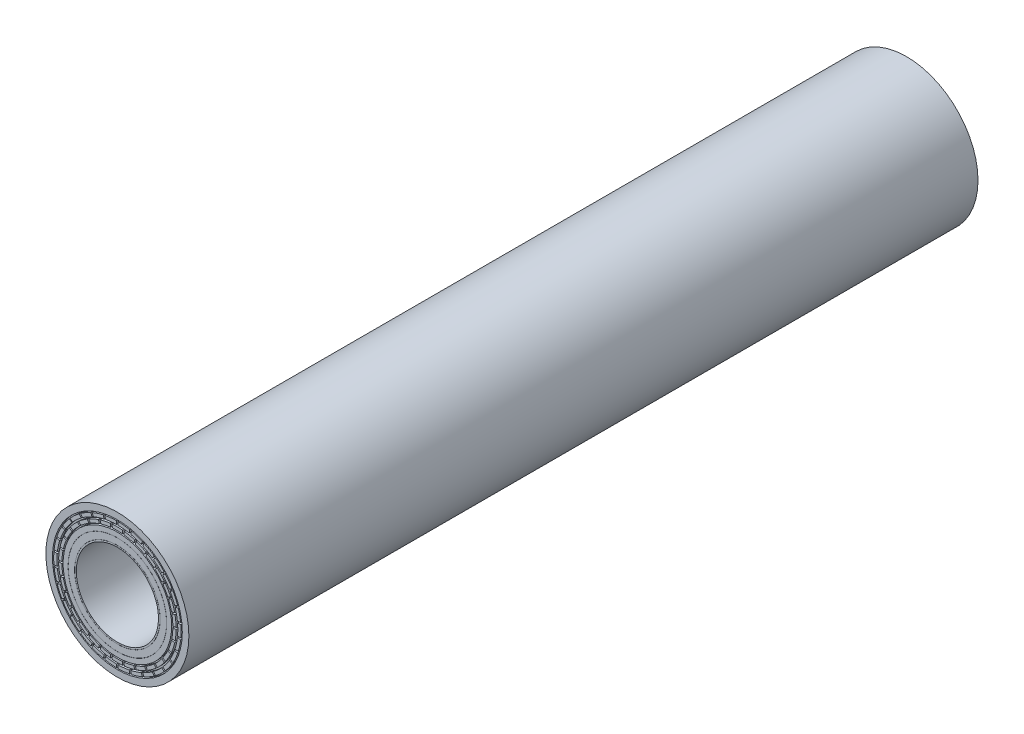
from build123d import *

# Parameters (mm, degrees)
SKETCH1_R           = 87
BOSS_EXTRUDE1_DEPTH = 960
SKETCH2_R           = 52
CUT_EXTRUDE1_DEPTH  = 961
SKETCH3_R           = 79
SKETCH3_R_2         = 77.5
SKETCH3_R_3         = 73.5
SKETCH3_R_4         = 71.5
SKETCH3_R_5         = 67.5
SKETCH3_R_6         = 66
CUT_EXTRUDE2_DEPTH  = 3
SKETCH7_W           = 1
SKETCH7_H           = 5.5
CUT_EXTRUDE5_DEPTH  = 3
SKETCH8_W           = 5.5
SKETCH8_H           = 2
CUT_EXTRUDE6_DEPTH  = 3
SKETCH9_R           = 52
SKETCH9_R_2         = 50
BOSS_EXTRUDE2_DEPTH = 960
SKETCH10_R          = 52
SKETCH10_R_2        = 51.9
CUT_EXTRUDE7_DEPTH  = 1
SKETCH11_R          = 52.1
SKETCH11_R_2        = 52
CUT_EXTRUDE8_DEPTH  = 1
SKETCH12_R          = 60
SKETCH12_R_2        = 59.9
CUT_EXTRUDE9_DEPTH  = 1


with BuildPart() as part:
    # Sketch1 → Boss-Extrude1 (new body)
    with BuildSketch(Plane.XY):
        with Locations((0, 87)):
            Circle(SKETCH1_R)
    extrude(amount=-BOSS_EXTRUDE1_DEPTH)

    # Sketch2 → Cut-Extrude1 (cut, through all)
    with BuildSketch(Plane.XY):
        with Locations((0, 87)):
            Circle(SKETCH2_R)
    extrude(amount=-CUT_EXTRUDE1_DEPTH, mode=Mode.SUBTRACT)

    # Sketch3 → Cut-Extrude2 (cut)
    with BuildSketch(Plane.XY):
        with Locations((0, 87)):
            Circle(SKETCH3_R)
        with Locations((0, 87)):
            Circle(SKETCH3_R_2, mode=Mode.SUBTRACT)
        with Locations((0, 87)):
            Circle(SKETCH3_R_3)
        with Locations((0, 87)):
            Circle(SKETCH3_R_4, mode=Mode.SUBTRACT)
        with Locations((0, 87)):
            Circle(SKETCH3_R_5)
        with Locations((0, 87)):
            Circle(SKETCH3_R_6, mode=Mode.SUBTRACT)
    cut_extrude2 = extrude(amount=-CUT_EXTRUDE2_DEPTH, mode=Mode.SUBTRACT)

    # Mirror2: Cut-Extrude2 across plane
    add(cut_extrude2.mirror(Plane.XY.offset(-480)), mode=Mode.SUBTRACT)

    # Sketch7 → Cut-Extrude5 (cut)
    with BuildSketch(Plane.XY):
        Polygon((-16.051745185, 16.292210638), (-17.195259485, 10.912398834), (-16.217111884, 10.704487143), (-15.073597584, 16.084298947), align=None)
        Polygon((-15.073597584, 16.084298947), (-16.217111884, 10.704487143), (-15.238964283, 10.496575452), (-14.095449984, 15.876387256), align=None)
        Polygon((14.095449984, 15.876387256), (15.238964283, 10.496575452), (16.217111884, 10.704487143), (15.073597584, 16.084298947), align=None)
        Polygon((15.073597584, 16.084298947), (16.217111884, 10.704487143), (17.195259485, 10.912398834), (16.051745185, 16.292210638), align=None)
        Polygon((28.574861165, 20.361217678), (30.811912702, 15.336717661), (31.72545816, 15.743454304), (29.488406623, 20.767954321), align=None)
        Polygon((29.488406623, 20.767954321), (31.72545816, 15.743454304), (32.639003618, 16.150190947), (30.401952081, 21.174690964), align=None)
        Polygon((-30.401952081, 21.174690964), (-32.639003618, 16.150190947), (-31.72545816, 15.743454304), (-29.488406623, 20.767954321), align=None)
        Polygon((-29.488406623, 20.767954321), (-31.72545816, 15.743454304), (-30.811912702, 15.336717661), (-28.574861165, 20.361217678), align=None)
        Polygon((-43.423447786, 28.93405316), (-46.656266673, 24.484459691), (-45.847249679, 23.896674439), (-42.614430791, 28.346267908), align=None)
        Polygon((-42.614430791, 28.346267908), (-45.847249679, 23.896674439), (-45.038232684, 23.308889186), (-41.805413797, 27.758482656), align=None)
        Polygon((-54.547130453, 39.231175864), (-58.634426994, 35.550957529), (-57.965296387, 34.807812704), (-53.877999847, 38.488031039), align=None)
        Polygon((-63.286841774, 51.616025404), (-68.049981495, 48.866025404), (-67.549981495, 48), (-62.786841774, 50.75), align=None)
        Polygon((-62.786841774, 50.75), (-67.549981495, 48), (-67.049981495, 47.133974596), (-62.286841774, 49.883974596), align=None)
        Polygon((-69.260614426, 65.547324424), (-74.491425265, 63.847730955), (-74.182408271, 62.896674439), (-68.951597431, 64.596267908), align=None)
        Polygon((-68.951597431, 64.596267908), (-74.182408271, 62.896674439), (-73.873391277, 61.945617922), (-68.642580437, 63.645211392), align=None)
        Polygon((-72.207365877, 80.416208308), (-77.677236302, 79.84130176), (-77.572707839, 78.846779865), (-72.102837414, 79.421686413), align=None)
        Polygon((-72.102837414, 79.421686413), (-77.572707839, 78.846779865), (-77.468179375, 77.85225797), (-71.998308951, 78.427164518), align=None)
        Polygon((-71.998308951, 95.572835482), (-77.468179375, 96.14774203), (-77.572707839, 95.153220135), (-72.102837414, 94.578313587), align=None)
        Polygon((-72.102837414, 94.578313587), (-77.572707839, 95.153220135), (-77.677236302, 94.15869824), (-72.207365877, 93.583791692), align=None)
        Polygon((-68.642580437, 110.354788608), (-73.873391277, 112.054382078), (-74.182408271, 111.103325561), (-68.951597431, 109.403732092), align=None)
        Polygon((-68.951597431, 109.403732092), (-74.182408271, 111.103325561), (-74.491425265, 110.152269045), (-69.260614426, 108.452675576), align=None)
        Polygon((-62.786841774, 123.25), (-67.549981495, 126), (-68.049981495, 125.133974596), (-63.286841774, 122.383974596), align=None)
        Polygon((-62.286841774, 124.116025404), (-67.049981495, 126.866025404), (-67.549981495, 126), (-62.786841774, 123.25), align=None)
        Polygon((-53.877999847, 135.511968961), (-57.965296387, 139.192187296), (-58.634426994, 138.449042471), (-54.547130453, 134.768824136), align=None)
        Polygon((-42.614430791, 145.653732092), (-45.847249679, 150.103325561), (-46.656266673, 149.515540309), (-43.423447786, 145.06594684), align=None)
        Polygon((-41.805413797, 146.241517344), (-45.038232684, 150.691110814), (-45.847249679, 150.103325561), (-42.614430791, 145.653732092), align=None)
        Polygon((-29.488406623, 153.232045679), (-31.72545816, 158.256545696), (-32.639003618, 157.849809053), (-30.401952081, 152.825309036), align=None)
        Polygon((-28.574861165, 153.638782322), (-30.811912702, 158.663282339), (-31.72545816, 158.256545696), (-29.488406623, 153.232045679), align=None)
        Polygon((-15.073597584, 157.915701053), (-16.217111884, 163.295512857), (-17.195259485, 163.087601166), (-16.051745185, 157.707789362), align=None)
        Polygon((-14.095449984, 158.123612744), (-15.238964283, 163.503424548), (-16.217111884, 163.295512857), (-15.073597584, 157.915701053), align=None)
        with Locations((-0.5, 162.25)):
            Rectangle(SKETCH7_W, SKETCH7_H)
        with Locations((0.5, 162.25)):
            Rectangle(SKETCH7_W, SKETCH7_H)
        Polygon((15.073597584, 157.915701053), (16.217111884, 163.295512857), (15.238964283, 163.503424548), (14.095449984, 158.123612744), align=None)
        Polygon((16.051745185, 157.707789362), (17.195259485, 163.087601166), (16.217111884, 163.295512857), (15.073597584, 157.915701053), align=None)
        Polygon((29.488406623, 153.232045679), (31.72545816, 158.256545696), (30.811912702, 158.663282339), (28.574861165, 153.638782322), align=None)
        Polygon((30.401952081, 152.825309036), (32.639003618, 157.849809053), (31.72545816, 158.256545696), (29.488406623, 153.232045679), align=None)
        Polygon((42.614430791, 145.653732092), (45.847249679, 150.103325561), (45.038232684, 150.691110814), (41.805413797, 146.241517344), align=None)
        Polygon((43.423447786, 145.06594684), (46.656266673, 149.515540309), (45.847249679, 150.103325561), (42.614430791, 145.653732092), align=None)
        Polygon((53.877999847, 135.511968961), (57.965296387, 139.192187296), (57.296165781, 139.935332121), (53.208869241, 136.255113786), align=None)
        Polygon((54.547130453, 134.768824136), (58.634426994, 138.449042471), (57.965296387, 139.192187296), (53.877999847, 135.511968961), align=None)
        Polygon((62.786841774, 123.25), (67.549981495, 126), (67.049981495, 126.866025404), (62.286841774, 124.116025404), align=None)
        Polygon((63.286841774, 122.383974596), (68.049981495, 125.133974596), (67.549981495, 126), (62.786841774, 123.25), align=None)
        Polygon((68.951597431, 109.403732092), (74.182408271, 111.103325561), (73.873391277, 112.054382078), (68.642580437, 110.354788608), align=None)
        Polygon((69.260614426, 108.452675576), (74.491425265, 110.152269045), (74.182408271, 111.103325561), (68.951597431, 109.403732092), align=None)
        Polygon((72.102837414, 94.578313587), (77.572707839, 95.153220135), (77.468179375, 96.14774203), (71.998308951, 95.572835482), align=None)
        Polygon((72.207365877, 93.583791692), (77.677236302, 94.15869824), (77.572707839, 95.153220135), (72.102837414, 94.578313587), align=None)
        Polygon((68.951597431, 64.596267908), (74.182408271, 62.896674439), (74.491425265, 63.847730955), (69.260614426, 65.547324424), align=None)
        Polygon((68.642580437, 63.645211392), (73.873391277, 61.945617922), (74.182408271, 62.896674439), (68.951597431, 64.596267908), align=None)
        Polygon((72.102837414, 79.421686413), (77.572707839, 78.846779865), (77.677236302, 79.84130176), (72.207365877, 80.416208308), align=None)
        Polygon((71.998308951, 78.427164518), (77.468179375, 77.85225797), (77.572707839, 78.846779865), (72.102837414, 79.421686413), align=None)
        Polygon((62.786841774, 50.75), (67.549981495, 48), (68.049981495, 48.866025404), (63.286841774, 51.616025404), align=None)
        Polygon((62.286841774, 49.883974596), (67.049981495, 47.133974596), (67.549981495, 48), (62.786841774, 50.75), align=None)
        Polygon((53.877999847, 38.488031039), (57.965296387, 34.807812704), (58.634426994, 35.550957529), (54.547130453, 39.231175864), align=None)
        Polygon((53.208869241, 37.744886214), (57.296165781, 34.064667879), (57.965296387, 34.807812704), (53.877999847, 38.488031039), align=None)
        Polygon((41.805413797, 27.758482656), (45.038232684, 23.308889186), (45.847249679, 23.896674439), (42.614430791, 28.346267908), align=None)
        Polygon((42.614430791, 28.346267908), (45.847249679, 23.896674439), (46.656266673, 24.484459691), (43.423447786, 28.93405316), align=None)
        with Locations((-0.5, 11.75)):
            Rectangle(SKETCH7_W, SKETCH7_H)
        with Locations((0.5, 11.75)):
            Rectangle(SKETCH7_W, SKETCH7_H)
    cut_extrude5 = extrude(amount=-CUT_EXTRUDE5_DEPTH, mode=Mode.SUBTRACT)

    # Mirror3: Cut-Extrude5 across plane
    add(cut_extrude5.mirror(Plane.XY.offset(-480)), mode=Mode.SUBTRACT)

    # Sketch8 → Cut-Extrude6 (cut)
    with BuildSketch(Plane.XY):
        with Locations((-69.25, 87)):
            Rectangle(SKETCH8_W, SKETCH8_H)
        Polygon((-64.838903758, 101.80427504), (-70.218715562, 102.94778934), (-70.634538944, 100.991494138), (-65.25472714, 99.847979839), align=None)
        Polygon((-60.34403629, 114.961532222), (-65.368536307, 117.198583759), (-66.182009593, 115.371492844), (-61.157509576, 113.134441307), align=None)
        Polygon((-53.211844874, 126.896736272), (-57.661438343, 130.129555159), (-58.837008847, 128.511521171), (-54.387415378, 125.278702283), align=None)
        Polygon((-43.754040497, 137.088261501), (-47.434258832, 141.175558041), (-48.920548483, 139.837296828), (-45.240330148, 135.750000288), align=None)
        Polygon((-32.383974596, 145.090689352), (-35.133974596, 149.853829072), (-36.866025404, 148.853829072), (-34.116025404, 144.090689352), align=None)
        Polygon((-19.59857361, 150.554275328), (-21.298167079, 155.785086168), (-23.200280111, 155.167052179), (-21.500686642, 149.936241339), align=None)
        Polygon((-5.956620912, 153.240234505), (-6.53152746, 158.71010493), (-8.520571251, 158.501048003), (-7.945664703, 153.031177579), align=None)
        Polygon((7.945664703, 153.031177579), (8.520571251, 158.501048003), (6.53152746, 158.71010493), (5.956620912, 153.240234505), align=None)
        Polygon((21.500686642, 149.936241339), (23.200280111, 155.167052179), (21.298167079, 155.785086168), (19.59857361, 150.554275328), align=None)
        Polygon((34.116025404, 144.090689352), (36.866025404, 148.853829072), (35.133974596, 149.853829072), (32.383974596, 145.090689352), align=None)
        Polygon((45.240330148, 135.750000288), (48.920548483, 139.837296828), (47.434258832, 141.175558041), (43.754040497, 137.088261501), align=None)
        Polygon((54.387415378, 125.278702283), (58.837008847, 128.511521171), (57.661438343, 130.129555159), (53.211844874, 126.896736272), align=None)
        Polygon((61.157509576, 113.134441307), (66.182009593, 115.371492844), (65.368536307, 117.198583759), (60.34403629, 114.961532222), align=None)
        Polygon((65.25472714, 99.847979839), (70.634538944, 100.991494138), (70.218715562, 102.94778934), (64.838903758, 101.80427504), align=None)
        with Locations((69.25, 87)):
            Rectangle(SKETCH8_W, SKETCH8_H)
        Polygon((64.838903758, 72.19572496), (70.218715562, 71.05221066), (70.634538944, 73.008505862), (65.25472714, 74.152020161), align=None)
        Polygon((60.34403629, 59.038467778), (65.368536307, 56.801416241), (66.182009593, 58.628507156), (61.157509576, 60.865558693), align=None)
        Polygon((53.211844874, 47.103263728), (57.661438343, 43.870444841), (58.837008847, 45.488478829), (54.387415378, 48.721297717), align=None)
        Polygon((43.754040497, 36.911738499), (47.434258832, 32.824441959), (48.920548483, 34.162703172), (45.240330148, 38.249999712), align=None)
        Polygon((32.383974596, 28.909310648), (35.133974596, 24.146170928), (36.866025404, 25.146170928), (34.116025404, 29.909310648), align=None)
        Polygon((19.59857361, 23.445724672), (21.298167079, 18.214913832), (23.200280111, 18.832947821), (21.500686642, 24.063758661), align=None)
        Polygon((5.956620912, 20.759765495), (6.53152746, 15.28989507), (8.520571251, 15.498951997), (7.945664703, 20.968822421), align=None)
        Polygon((-7.945664703, 20.968822421), (-8.520571251, 15.498951997), (-6.53152746, 15.28989507), (-5.956620912, 20.759765495), align=None)
        Polygon((-21.500686642, 24.063758661), (-23.200280111, 18.832947821), (-21.298167079, 18.214913832), (-19.59857361, 23.445724672), align=None)
        Polygon((-34.116025404, 29.909310648), (-36.866025404, 25.146170928), (-35.133974596, 24.146170928), (-32.383974596, 28.909310648), align=None)
        Polygon((-45.240330148, 38.249999712), (-48.920548483, 34.162703172), (-47.434258832, 32.824441959), (-43.754040497, 36.911738499), align=None)
        Polygon((-54.387415378, 48.721297717), (-58.837008847, 45.488478829), (-57.661438343, 43.870444841), (-53.211844874, 47.103263728), align=None)
        Polygon((-61.157509576, 60.865558693), (-66.182009593, 58.628507156), (-65.368536307, 56.801416241), (-60.34403629, 59.038467778), align=None)
        Polygon((-65.25472714, 74.152020161), (-70.634538944, 73.008505862), (-70.218715562, 71.05221066), (-64.838903758, 72.19572496), align=None)
    cut_extrude6 = extrude(amount=-CUT_EXTRUDE6_DEPTH, mode=Mode.SUBTRACT)

    # Mirror4: Cut-Extrude6 across plane
    add(cut_extrude6.mirror(Plane.XY.offset(-480)), mode=Mode.SUBTRACT)

    # Sketch9 → Boss-Extrude2 (add)
    with BuildSketch(Plane.XY):
        with Locations((0, 87)):
            Circle(SKETCH9_R)
        with Locations((0, 87)):
            Circle(SKETCH9_R_2, mode=Mode.SUBTRACT)
    extrude(amount=-BOSS_EXTRUDE2_DEPTH)

    # Sketch10 → Cut-Extrude7 (cut)
    with BuildSketch(Plane.XY):
        with Locations((0, 87)):
            Circle(SKETCH10_R)
        with Locations((0, 87)):
            Circle(SKETCH10_R_2, mode=Mode.SUBTRACT)
    extrude(amount=-CUT_EXTRUDE7_DEPTH, mode=Mode.SUBTRACT)

    # Sketch11 → Cut-Extrude8 (cut)
    with BuildSketch(Plane(origin=(0, 0, -960), x_dir=(-1, 0, 0), z_dir=(0, 0, -1))):
        with Locations((0, 87)):
            Circle(SKETCH11_R)
        with Locations((0, 87)):
            Circle(SKETCH11_R_2, mode=Mode.SUBTRACT)
    extrude(amount=-CUT_EXTRUDE8_DEPTH, mode=Mode.SUBTRACT)

    # Sketch12 → Cut-Extrude9 (cut)
    with BuildSketch(Plane(origin=(0, 0, -960), x_dir=(-1, 0, 0), z_dir=(0, 0, -1))):
        with Locations((0, 87)):
            Circle(SKETCH12_R)
        with Locations((0, 87)):
            Circle(SKETCH12_R_2, mode=Mode.SUBTRACT)
    cut_extrude9 = extrude(amount=-CUT_EXTRUDE9_DEPTH, mode=Mode.SUBTRACT)

    # Mirror6: Cut-Extrude9 across plane
    add(cut_extrude9.mirror(Plane.XY.offset(-480)), mode=Mode.SUBTRACT)


solid = part.part
